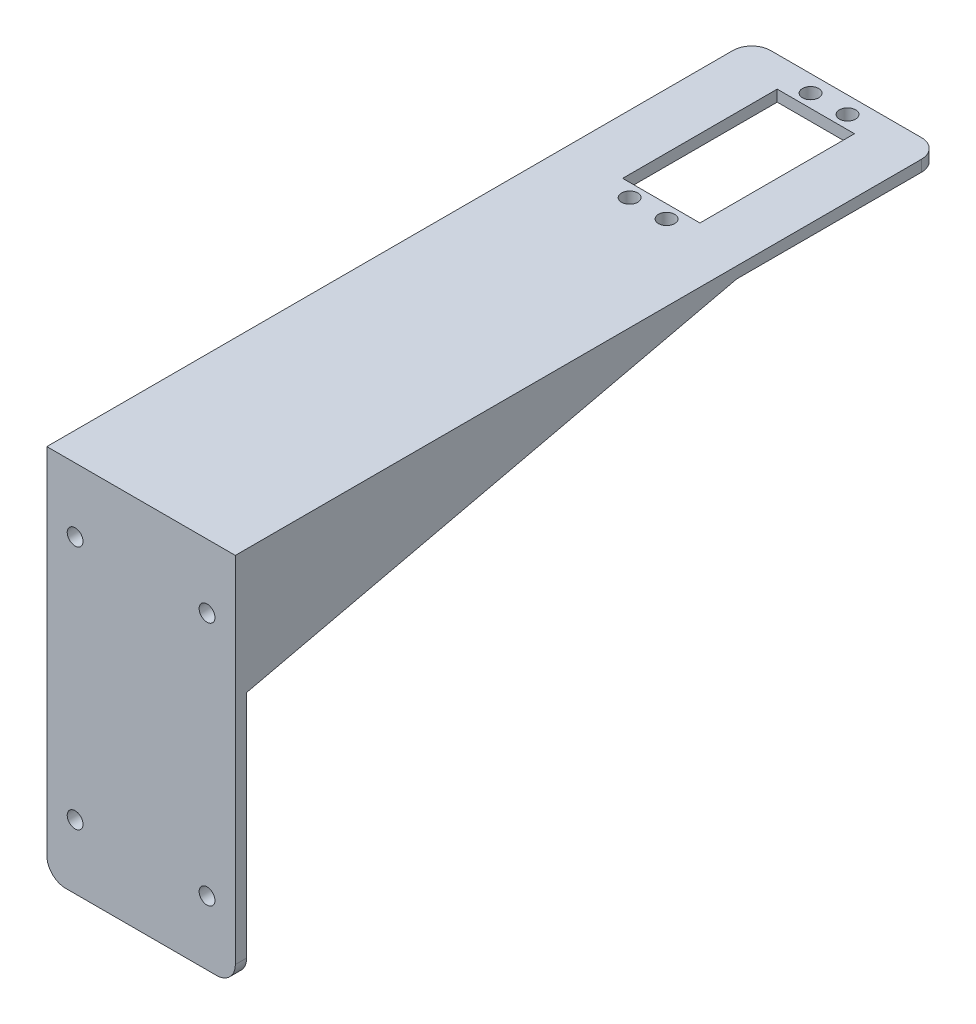
from build123d import *

# Parameters (mm, degrees)
SKETCH_1_W          = 50
SKETCH_1_H          = 187
EXTRUDE_1_DEPTH     = 3
SKETCH_4_R          = 2.15
SKETCH_4_W          = 20.5
SKETCH_4_H          = 41
CUT_EXTRUDE_2_DEPTH = 4
SKETCH_5_W          = 50
SKETCH_5_H          = 3
EXTRUDE_2_DEPTH     = 96
SKETCH_6_R          = 2.1
CUT_EXTRUDE_3_DEPTH = 188
FILLET_1_R          = 5
EXTRUDE_3_DEPTH     = 2
EXTRUDE_4_DEPTH     = 2


with BuildPart() as part:
    # 草图1 → 凸台-拉伸1 (new body)
    with BuildSketch(Plane(origin=(0, 0, 0), x_dir=(1, 0, 0), z_dir=(0, 1, 0))):
        Rectangle(SKETCH_1_W, SKETCH_1_H)
    extrude(amount=EXTRUDE_1_DEPTH)

    # 草图4 → 切除-拉伸2 (cut, through all)
    with BuildSketch(Plane.XZ):
        with Locations((-4.9, -89)):
            Circle(SKETCH_4_R)
        with Locations((4.9, -89)):
            Circle(SKETCH_4_R)
        with Locations((4.9, -41)):
            Circle(SKETCH_4_R)
        with Locations((-4.9, -41)):
            Circle(SKETCH_4_R)
        with Locations((0, -65)):
            Rectangle(SKETCH_4_W, SKETCH_4_H)
    extrude(amount=-CUT_EXTRUDE_2_DEPTH, mode=Mode.SUBTRACT)

    # 草图5 → 凸台-拉伸2 (add)
    with BuildSketch(Plane.XZ):
        with Locations((0, 92)):
            Rectangle(SKETCH_5_W, SKETCH_5_H)
    extrude(amount=EXTRUDE_2_DEPTH)

    # 草图6 → 切除-拉伸3 (cut, through all)
    with BuildSketch(Plane.XY.offset(93.5)):
        with Locations((-17.5, -14)):
            Circle(SKETCH_6_R)
        with Locations((17.5, -14)):
            Circle(SKETCH_6_R)
        with Locations((17.5, -79)):
            Circle(SKETCH_6_R)
        with Locations((-17.5, -79)):
            Circle(SKETCH_6_R)
    extrude(amount=-CUT_EXTRUDE_3_DEPTH, mode=Mode.SUBTRACT)

    # 圆角1
    fillet_1_edges = [part.edges().sort_by_distance(p)[0] for p in [
        (-25, -96, 92),
        (25, -96, 92),
        (-25, 1.5, -93.5),
        (25, 1.5, -93.5),
    ]]
    fillet(fillet_1_edges, radius=FILLET_1_R)

    # 草图7 → 凸台-拉伸3 (add)
    with BuildSketch(Plane(origin=(25, 0, 0), x_dir=(0, 0, -1), z_dir=(1, 0, 0))):
        Polygon((39.5, 0), (-90.5, -30), (-90.5, 0), align=None)
    extrude(amount=-EXTRUDE_3_DEPTH)

    # 草图9 → 凸台-拉伸4 (add)
    with BuildSketch(Plane.ZY.offset(25)):
        Polygon((-39.5, 0), (90.5, -30), (90.5, 0), align=None)
    extrude(amount=-EXTRUDE_4_DEPTH)


solid = part.part
